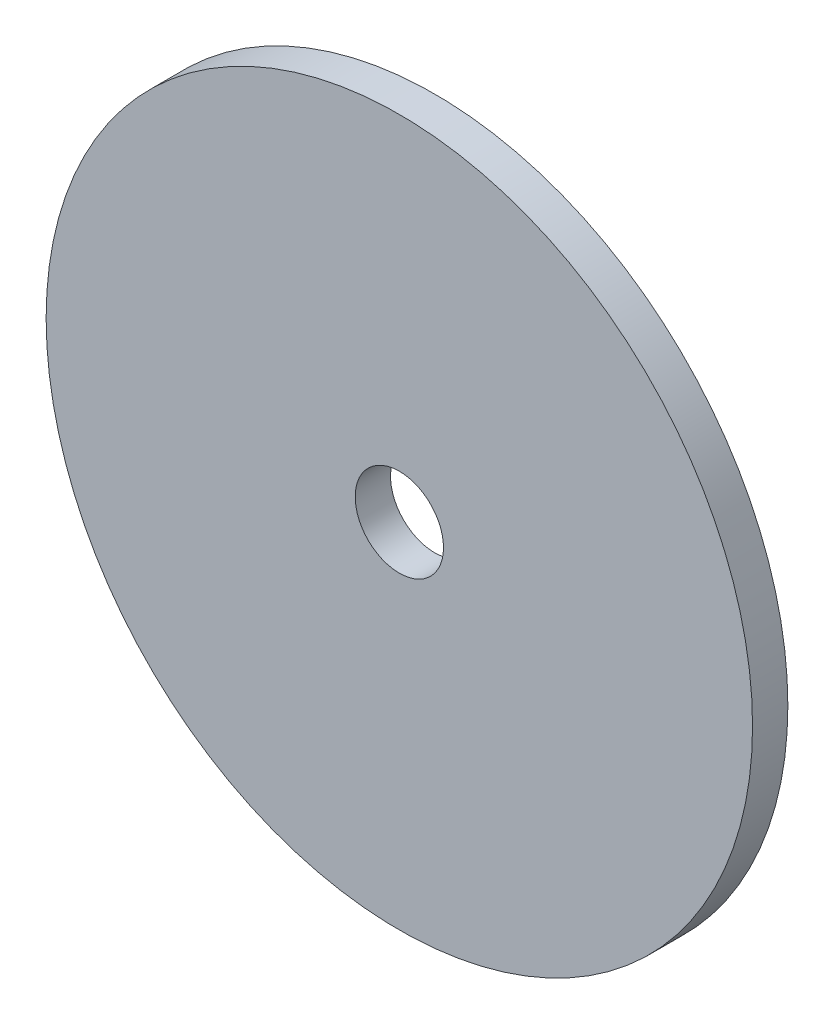
from build123d import *

# Parameters (mm, degrees)
SKETCH1_R           = 25.4
SKETCH1_R_2         = 3.175
BOSS_EXTRUDE1_DEPTH = 2.54


with BuildPart() as part:
    # Sketch1 → Boss-Extrude1 (new body)
    with BuildSketch(Plane.XY):
        Circle(SKETCH1_R)
        Circle(SKETCH1_R_2, mode=Mode.SUBTRACT)
    extrude(amount=BOSS_EXTRUDE1_DEPTH)


solid = part.part
